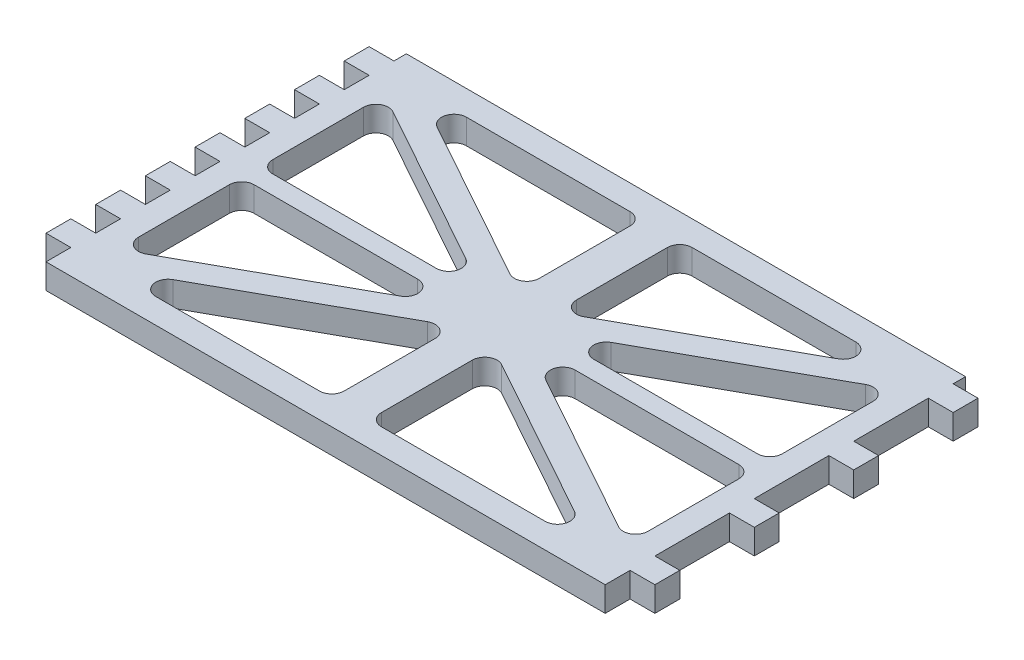
from build123d import *

# Parameters (mm, degrees)
BOSS_EXTRUDE1_DEPTH = 4
CUT_EXTRUDE1_DEPTH  = 10


with BuildPart() as part:
    # Sketch1 → Boss-Extrude1 (new body)
    with BuildSketch(Plane(origin=(0, 0, 0), x_dir=(1, 0, 0), z_dir=(0, 1, 0))):
        Polygon((-10.4, 13.35), (-10.4, 11.35), (-14.4, 11.35), (-14.4, 7.35), (-10.4, 7.35), (-10.4, 3.35), (-14.4, 3.35), (-14.4, -0.65), (-10.4, -0.65), (-10.4, -4.65), (-14.4, -4.65), (-14.4, -8.65), (-10.4, -8.65), (-10.4, -12.65), (-14.4, -12.65), (-14.4, -16.65), (-10.4, -16.65), (-10.4, -20.65), (-14.4, -20.65), (-14.4, -24.65), (-10.4, -24.65), (-10.4, -28.65), (-14.4, -28.65), (-14.4, -32.65), (-10.4, -32.65), (-10.4, -36.65), (-14.4, -36.65), (-14.4, -40.65), (-10.4, -40.65), (-10.4, -44.65), (79.6, -44.65), (79.6, -40.65), (83.6, -40.65), (83.6, -36.65), (79.6, -36.65), (79.6, -24.65), (83.6, -24.65), (83.6, -20.65), (79.6, -20.65), (79.6, -8.65), (83.6, -8.65), (83.6, -4.65), (79.6, -4.65), (79.6, 7.35), (83.6, 7.35), (83.6, 11.35), (79.6, 11.35), (79.6, 13.35), align=None)
    extrude(amount=-BOSS_EXTRUDE1_DEPTH)

    # Sketch2 → Cut-Extrude1 (cut)
    with BuildSketch(Plane(origin=(0, 0, 0), x_dir=(1, 0, 0), z_dir=(0, 1, 0))):
        with BuildLine():
            Line((3.269007855, 9.35), (29.6, 9.35))
            ThreePointArc((29.6, 9.35), (31.014213562, 8.764213562), (31.6, 7.35))
            Line((31.6, 7.35), (31.6, -7.255623888))
            ThreePointArc((31.6, -7.255623888), (30.61482352, -8.979031334), (28.629866776, -9.004578298))
            Line((28.629866776, -9.004578298), (2.29887463, 5.60104559))
            ThreePointArc((2.29887463, 5.60104559), (1.332786171, 7.851044499), (3.269007855, 9.35))
        make_face()
        with BuildLine():
            ThreePointArc((-6.4, 2.455623888), (-5.41482352, 4.179031334), (-3.429866776, 4.204578298))
            Line((-3.429866776, 4.204578298), (22.90112537, -10.40104559))
            ThreePointArc((22.90112537, -10.40104559), (23.867213829, -12.651044499), (21.930992145, -14.15))
            Line((21.930992145, -14.15), (-4.4, -14.15))
            ThreePointArc((-4.4, -14.15), (-5.814213562, -13.564213562), (-6.4, -12.15))
            Line((-6.4, -12.15), (-6.4, 2.455623888))
        make_face()
        with BuildLine():
            ThreePointArc((-6.4, -19.15), (-5.814213562, -17.735786438), (-4.4, -17.15))
            Line((-4.4, -17.15), (21.930992145, -17.15))
            ThreePointArc((21.930992145, -17.15), (23.867213829, -18.648955501), (22.90112537, -20.89895441))
            Line((22.90112537, -20.89895441), (-3.429866776, -35.504578298))
            ThreePointArc((-3.429866776, -35.504578298), (-5.41482352, -35.479031334), (-6.4, -33.755623888))
            Line((-6.4, -33.755623888), (-6.4, -19.15))
        make_face()
        with BuildLine():
            Line((31.6, -38.65), (31.6, -24.044376112))
            ThreePointArc((31.6, -24.044376112), (30.61482352, -22.320968666), (28.629866776, -22.295421702))
            Line((28.629866776, -22.295421702), (2.29887463, -36.90104559))
            ThreePointArc((2.29887463, -36.90104559), (1.332786171, -39.151044499), (3.269007855, -40.65))
            Line((3.269007855, -40.65), (29.6, -40.65))
            ThreePointArc((29.6, -40.65), (31.014213562, -40.064213562), (31.6, -38.65))
        make_face()
        with BuildLine():
            Line((65.930992145, -40.65), (39.6, -40.65))
            ThreePointArc((39.6, -40.65), (38.185786438, -40.064213562), (37.6, -38.65))
            Line((37.6, -38.65), (37.6, -24.044376112))
            ThreePointArc((37.6, -24.044376112), (38.58517648, -22.320968666), (40.570133224, -22.295421702))
            Line((40.570133224, -22.295421702), (66.90112537, -36.90104559))
            ThreePointArc((66.90112537, -36.90104559), (67.867213829, -39.151044499), (65.930992145, -40.65))
        make_face()
        with BuildLine():
            ThreePointArc((75.6, -33.755623888), (74.61482352, -35.479031334), (72.629866776, -35.504578298))
            Line((72.629866776, -35.504578298), (46.29887463, -20.89895441))
            ThreePointArc((46.29887463, -20.89895441), (45.332786171, -18.648955501), (47.269007855, -17.15))
            Line((47.269007855, -17.15), (73.6, -17.15))
            ThreePointArc((73.6, -17.15), (75.014213562, -17.735786438), (75.6, -19.15))
            Line((75.6, -19.15), (75.6, -33.755623888))
        make_face()
        with BuildLine():
            ThreePointArc((75.6, -12.15), (75.014213562, -13.564213562), (73.6, -14.15))
            Line((73.6, -14.15), (47.269007855, -14.15))
            ThreePointArc((47.269007855, -14.15), (45.332786171, -12.651044499), (46.29887463, -10.40104559))
            Line((46.29887463, -10.40104559), (72.629866776, 4.204578298))
            ThreePointArc((72.629866776, 4.204578298), (74.61482352, 4.179031334), (75.6, 2.455623888))
            Line((75.6, 2.455623888), (75.6, -12.15))
        make_face()
        with BuildLine():
            Line((37.6, 7.35), (37.6, -7.255623888))
            ThreePointArc((37.6, -7.255623888), (38.58517648, -8.979031334), (40.570133224, -9.004578298))
            Line((40.570133224, -9.004578298), (66.90112537, 5.60104559))
            ThreePointArc((66.90112537, 5.60104559), (67.867213829, 7.851044499), (65.930992145, 9.35))
            Line((65.930992145, 9.35), (39.6, 9.35))
            ThreePointArc((39.6, 9.35), (38.185786438, 8.764213562), (37.6, 7.35))
        make_face()
    extrude(amount=-CUT_EXTRUDE1_DEPTH, mode=Mode.SUBTRACT)


solid = part.part
